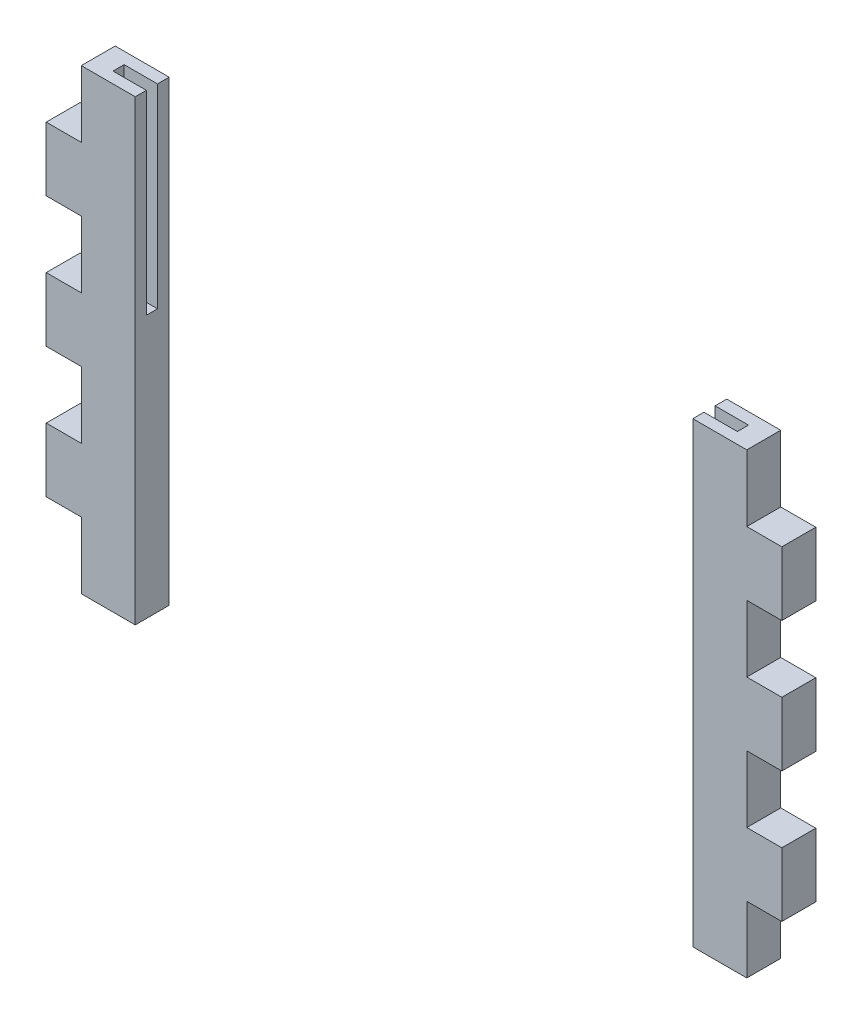
from build123d import *

# Parameters (mm, degrees)
ESQUISSE1_W             = 40
ESQUISSE1_H             = 205.5
BOSS_EXTRU_1_DEPTH      = 15.25
BOSS_EXTRU_1_2_DEPTH    = 15.25
ENL_V_START             = -5.25
ESQUISSE2_W             = 15
ESQUISSE2_H             = 87.5
ENL_V_MAT_EXTRU_1_DEPTH = 5
ESQUISSE3_W             = 15.75
ESQUISSE3_H             = 29.857142857
ESQUISSE3_H_2           = 29.857142858
ENL_V_MAT_EXTRU_2_DEPTH = 15.25


with BuildPart() as part:
    # Esquisse1 → Boss.-Extru.1 (new body)
    with BuildSketch(Plane.XY):
        with Locations((-143.085152838, 82.563864629)):
            Rectangle(ESQUISSE1_W, ESQUISSE1_H)
    extrude(amount=BOSS_EXTRU_1_DEPTH)


with BuildPart() as body_2:
    # Esquisse1 → Boss.-Extru.1 2 (new body)
    with BuildSketch(Plane.XY):
        with Locations((147.414847162, 82.563864629)):
            Rectangle(ESQUISSE1_W, ESQUISSE1_H)
    extrude(amount=BOSS_EXTRU_1_2_DEPTH)


with BuildPart() as enl_v_mat_extru_1_tool:
    # Esquisse2 → Enlèv. mat.-Extru.1 (new body)
    with BuildSketch(Plane(origin=(0, 0, 0), x_dir=(-1, 0, 0), z_dir=(0, 0, -1)).offset(ENL_V_START)):
        with Locations((130.585152838, 141.563864629)):
            Rectangle(ESQUISSE2_W, ESQUISSE2_H)
        with Locations((-134.914847162, 141.563864629)):
            Rectangle(ESQUISSE2_W, ESQUISSE2_H)
    extrude(amount=-ENL_V_MAT_EXTRU_1_DEPTH)


with BuildPart() as part_1:
    add(part.part)

    # Enlèv. mat.-Extru.1: cut by enl_v_mat_extru_1_tool
    add(enl_v_mat_extru_1_tool.part, mode=Mode.SUBTRACT)

    # Esquisse3 → Enlèv. mat.-Extru.2 (cut)
    with BuildSketch(Plane(origin=(0, 0, 0), x_dir=(-1, 0, 0), z_dir=(0, 0, -1))):
        with Locations((155.210152838, 170.385293201)):
            Rectangle(ESQUISSE3_W, ESQUISSE3_H)
        with Locations((155.210152838, 111.837674152)):
            Rectangle(ESQUISSE3_W, ESQUISSE3_H)
        with Locations((155.210152838, 53.290055105)):
            Rectangle(ESQUISSE3_W, ESQUISSE3_H_2)
        with Locations((155.210152838, -5.257563943)):
            Rectangle(ESQUISSE3_W, ESQUISSE3_H)
    enl_v_mat_extru_2 = extrude(amount=-ENL_V_MAT_EXTRU_2_DEPTH, mode=Mode.SUBTRACT)


with BuildPart() as body_2_1:
    add(body_2.part)

    # Enlèv. mat.-Extru.1: cut by enl_v_mat_extru_1_tool
    add(enl_v_mat_extru_1_tool.part, mode=Mode.SUBTRACT)

    # Symétrie3: Enlèv. mat.-Extru.2 across plane
    add(enl_v_mat_extru_2.mirror(Plane.ZY.offset(-2.164847162)), mode=Mode.SUBTRACT)


solid = Compound([part_1.part, body_2_1.part])
